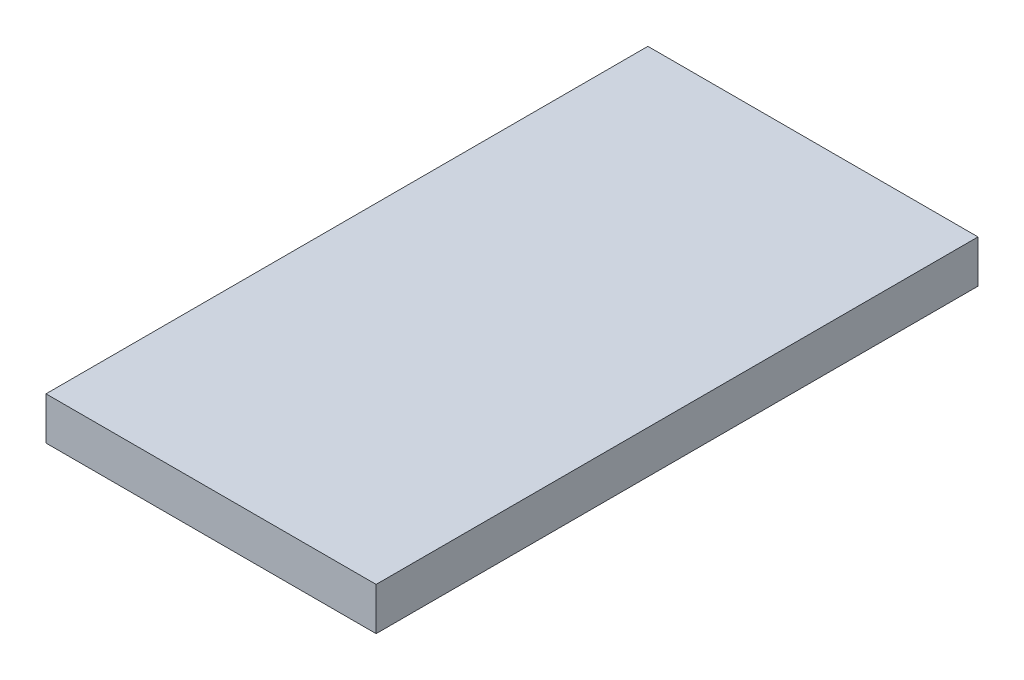
from build123d import *

# Parameters (mm, degrees)
SKETCH1_W           = 23.2
SKETCH1_H           = 42.3
BOSS_EXTRUDE1_DEPTH = 3


with BuildPart() as part:
    # Sketch1 → Boss-Extrude1 (new body)
    with BuildSketch(Plane(origin=(0, 0, 0), x_dir=(1, 0, 0), z_dir=(0, 1, 0))):
        with Locations((11.6, -21.15)):
            Rectangle(SKETCH1_W, SKETCH1_H)
    extrude(amount=BOSS_EXTRUDE1_DEPTH)


solid = part.part
